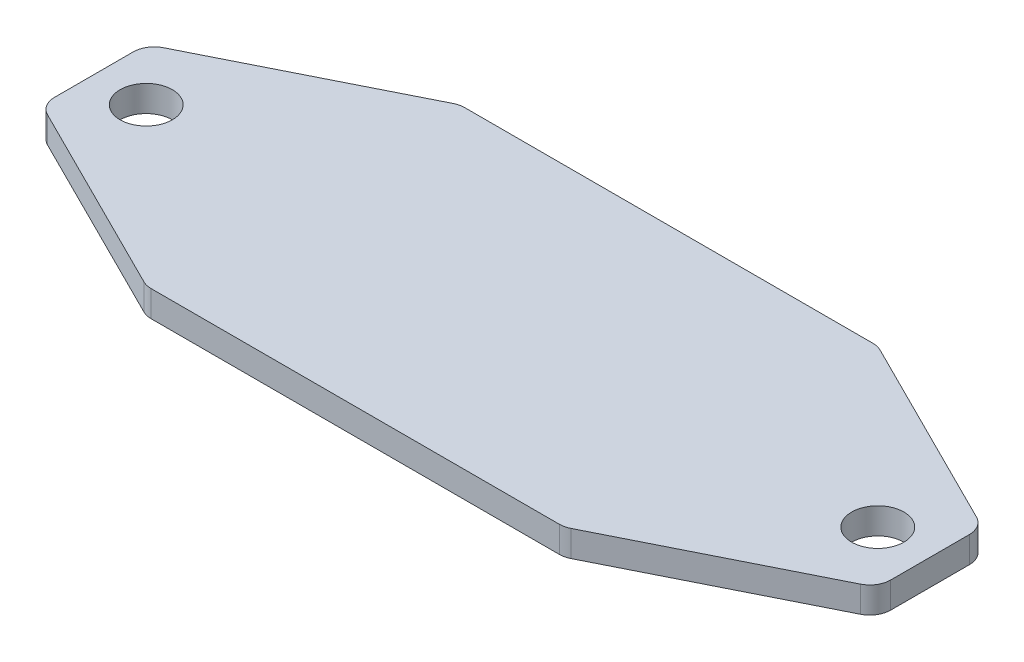
from build123d import *

# Parameters (mm, degrees)
SKETCH1_R           = 3.175
BOSS_EXTRUDE1_DEPTH = 3.175


with BuildPart() as part:
    # Sketch1 → Boss-Extrude1 (new body)
    with BuildSketch(Plane(origin=(0, 3.175, 0), x_dir=(1, 0, 0), z_dir=(0, 1, 0))):
        with BuildLine():
            Line((67.238500214, -4.780193669), (67.238500214, 4.780193669))
            ThreePointArc((67.238500214, 4.780193669), (66.859153267, 6.115550693), (65.834422746, 7.052038734))
            Line((65.834422746, 7.052038734), (42.374810083, 18.781845065))
            ThreePointArc((42.374810083, 18.781845065), (41.822459969, 18.982052433), (41.238887551, 19.05))
            Line((41.238887551, 19.05), (-8.361887124, 19.05))
            ThreePointArc((-8.361887124, 19.05), (-8.945459542, 18.982052433), (-9.497809656, 18.781845065))
            Line((-9.497809656, 18.781845065), (-32.957422319, 7.052038734))
            ThreePointArc((-32.957422319, 7.052038734), (-33.98215284, 6.115550693), (-34.361499786, 4.780193669))
            Line((-34.361499786, 4.780193669), (-34.361499786, -4.780193669))
            ThreePointArc((-34.361499786, -4.780193669), (-33.98215284, -6.115550693), (-32.957422319, -7.052038734))
            Line((-32.957422319, -7.052038734), (-9.497809656, -18.781845065))
            ThreePointArc((-9.497809656, -18.781845065), (-8.945459542, -18.982052433), (-8.361887124, -19.05))
            Line((-8.361887124, -19.05), (41.238887551, -19.05))
            ThreePointArc((41.238887551, -19.05), (41.822459969, -18.982052433), (42.374810083, -18.781845065))
            Line((42.374810083, -18.781845065), (65.834422746, -7.052038734))
            ThreePointArc((65.834422746, -7.052038734), (66.859153267, -6.115550693), (67.238500214, -4.780193669))
        make_face()
        with Locations((-28.011499786, 0)):
            Circle(SKETCH1_R, mode=Mode.SUBTRACT)
        with Locations((60.888500214, 0)):
            Circle(SKETCH1_R, mode=Mode.SUBTRACT)
    extrude(amount=-BOSS_EXTRUDE1_DEPTH)


solid = part.part
